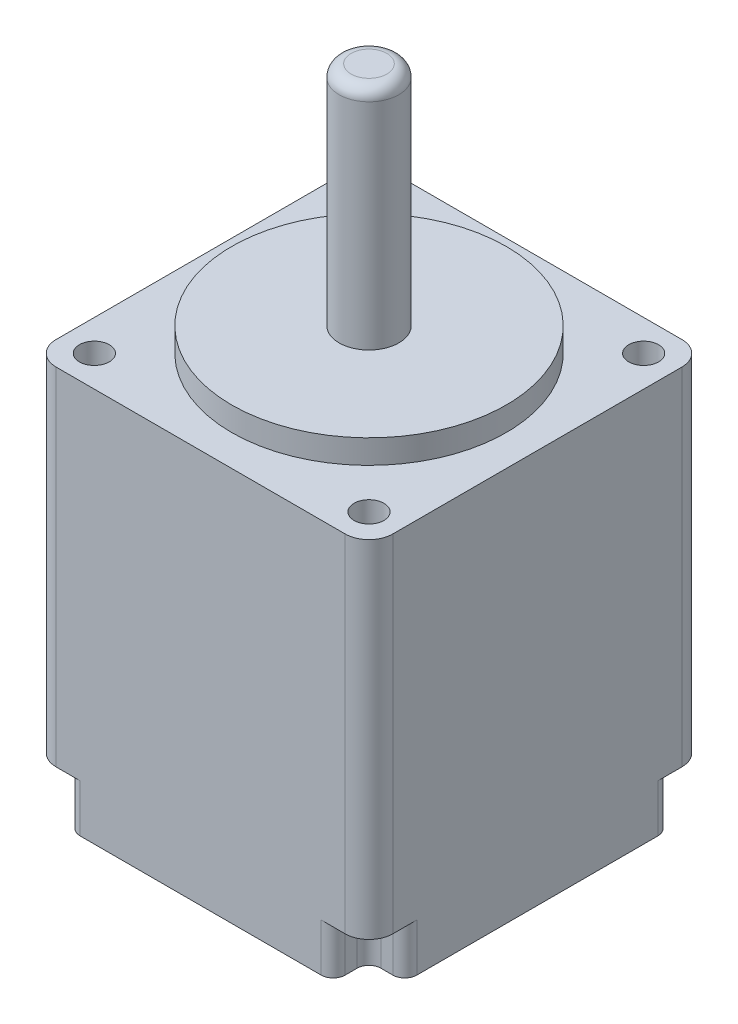
from build123d import *

# Parameters (mm, degrees)
SKETCH1_W               = 28.2
SKETCH1_H               = 28.2
BOSS_EXTRUDE1_DEPTH     = 33
SKETCH2_R               = 11.5
BOSS_EXTRUDE2_DEPTH     = 2
SKETCH3_R               = 2.5
BOSS_EXTRUDE3_DEPTH     = 19
SKETCH4_R               = 1.25
CUT_EXTRUDE1_DEPTH      = 8
MIRROR2_COPY_1_SKETCH_R = 1.25
MIRROR2_COPY_1_DEPTH    = 8
SKETCH5_W               = 3
SKETCH5_H               = 3
CUT_EXTRUDE2_DEPTH      = 4
MIRROR4_COPY_1_SKETCH_W = 3
MIRROR4_COPY_1_SKETCH_H = 3
MIRROR4_COPY_1_DEPTH    = 4
SKETCH6_R               = 2.5
CUT_EXTRUDE3_DEPTH      = 4
FILLET1_R               = 2
FILLET2_R               = 1
FILLET3_R               = 1


with BuildPart() as part:
    # Sketch1 → Boss-Extrude1 (new body)
    with BuildSketch(Plane(origin=(0, 0, 0), x_dir=(1, 0, 0), z_dir=(0, 1, 0))):
        Rectangle(SKETCH1_W, SKETCH1_H)
    extrude(amount=BOSS_EXTRUDE1_DEPTH)

    # Sketch2 → Boss-Extrude2 (add)
    with BuildSketch(Plane(origin=(0, 33, 0), x_dir=(1, 0, 0), z_dir=(0, 1, 0))):
        Circle(SKETCH2_R)
    extrude(amount=BOSS_EXTRUDE2_DEPTH)

    # Sketch3 → Boss-Extrude3 (add)
    with BuildSketch(Plane(origin=(0, 35, 0), x_dir=(1, 0, 0), z_dir=(0, 1, 0))):
        Circle(SKETCH3_R)
    extrude(amount=BOSS_EXTRUDE3_DEPTH)

    # Sketch4 → Cut-Extrude1 (cut)
    with BuildSketch(Plane(origin=(0, 33, 0), x_dir=(1, 0, 0), z_dir=(0, 1, 0))):
        with Locations((-11.5, 11.5)):
            Circle(SKETCH4_R)
    cut_extrude1 = extrude(amount=-CUT_EXTRUDE1_DEPTH, mode=Mode.SUBTRACT)

    # Mirror1: Cut-Extrude1 across plane
    add(cut_extrude1.mirror(Plane(origin=(0, 0, 0), x_dir=(0, 0, 1), z_dir=(1, 0, 0))), mode=Mode.SUBTRACT)

    # Mirror2: Cut-Extrude1 across plane
    add(cut_extrude1.mirror(Plane.XY), mode=Mode.SUBTRACT)

    # Mirror2 copy 1 sketch → Mirror2 copy 1 (cut)
    with BuildSketch(Plane(origin=(0, 33, 0), x_dir=(-1, 0, 0), z_dir=(0, 1, 0))):
        with Locations((-11.5, 11.5)):
            Circle(MIRROR2_COPY_1_SKETCH_R)
    extrude(amount=-MIRROR2_COPY_1_DEPTH, mode=Mode.SUBTRACT)

    # Sketch5 → Cut-Extrude2 (cut)
    with BuildSketch(Plane.XZ):
        with Locations((-12.6, 12.6)):
            Rectangle(SKETCH5_W, SKETCH5_H)
    cut_extrude2 = extrude(amount=-CUT_EXTRUDE2_DEPTH, mode=Mode.SUBTRACT)

    # Mirror3: Cut-Extrude2 across plane
    add(cut_extrude2.mirror(Plane(origin=(0, 0, 0), x_dir=(0, 0, 1), z_dir=(1, 0, 0))), mode=Mode.SUBTRACT)

    # Mirror4: Cut-Extrude2 across plane
    add(cut_extrude2.mirror(Plane.XY), mode=Mode.SUBTRACT)

    # Mirror4 copy 1 sketch → Mirror4 copy 1 (cut)
    with BuildSketch(Plane(origin=(0, 0, 0), x_dir=(-1, 0, 0), z_dir=(0, -1, 0))):
        with Locations((-12.6, 12.6)):
            Rectangle(MIRROR4_COPY_1_SKETCH_W, MIRROR4_COPY_1_SKETCH_H)
    extrude(amount=-MIRROR4_COPY_1_DEPTH, mode=Mode.SUBTRACT)

    # Sketch6 → Cut-Extrude3 (cut)
    with BuildSketch(Plane.XZ):
        Circle(SKETCH6_R)
    extrude(amount=-CUT_EXTRUDE3_DEPTH, mode=Mode.SUBTRACT)

    # Fillet1
    fillet1_edges = [part.edges().sort_by_distance(p)[0] for p in [
        (14.1, 18.5, 14.1),
        (-14.1, 18.5, 14.1),
        (-14.1, 18.5, -14.1),
        (14.1, 18.5, -14.1),
    ]]
    fillet(fillet1_edges, radius=FILLET1_R)

    # Fillet2
    fillet2_edges = [part.edges().sort_by_distance(p)[0] for p in [
        (-14.1, 2, 11.1),
        (-11.1, 2, 14.1),
        (-11.1, 2, 11.1),
        (14.1, 2, 11.1),
        (11.1, 2, 11.1),
        (11.1, 2, 14.1),
        (-14.1, 2, -11.1),
        (-11.1, 2, -11.1),
        (-11.1, 2, -14.1),
        (14.1, 2, -11.1),
        (11.1, 2, -14.1),
        (11.1, 2, -11.1),
    ]]
    fillet(fillet2_edges, radius=FILLET2_R)

    # Fillet3
    fillet3_edges = [part.edges().sort_by_distance(p)[0] for p in [
        (-2.5, 54, 0),
    ]]
    fillet(fillet3_edges, radius=FILLET3_R)


solid = part.part
